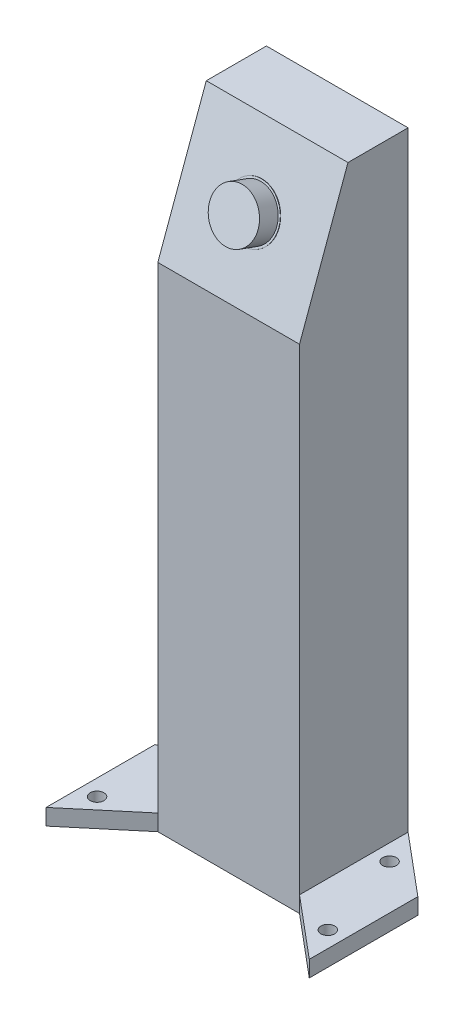
from build123d import *

# Parameters (mm, degrees)
AUFSATZ_LINEAR_AUSTRAGEN1_DEPTH = 35
SKIZZE3_R                       = 6
AUFSATZ_LINEAR_AUSTRAGEN2_DEPTH = 5
SKIZZE4_R                       = 6.5
AUFSATZ_LINEAR_AUSTRAGEN3_DEPTH = 0.1
SKIZZE9_R                       = 1.7
AUFSATZ_LINEAR_AUSTRAGEN4_DEPTH = 4


with BuildPart() as part:
    # Skizze1 → Aufsatz-Linear austragen1 (new body)
    with BuildSketch(Plane(origin=(0, 0, 0), x_dir=(0, 0, -1), z_dir=(1, 0, 0))):
        Polygon((0, 0), (11.970705016, 0), (26.82, 0), (26.82, 154.689241728), (11.970705016, 154.689241728), (0, 121.8), align=None)
    extrude(amount=AUFSATZ_LINEAR_AUSTRAGEN1_DEPTH)

    # Skizze3 → Aufsatz-Linear austragen2 (add)
    with BuildSketch(Plane(origin=(0, 14.247893414, 39.14576543), x_dir=(1, 0, 0), z_dir=(0, 0.342020143, 0.939692621))):
        with Locations((17.5, 131.954561212)):
            Circle(SKIZZE3_R)
    extrude(amount=AUFSATZ_LINEAR_AUSTRAGEN2_DEPTH)

    # Skizze4 → Aufsatz-Linear austragen3 (add)
    with BuildSketch(Plane(origin=(0, 14.247893414, 39.14576543), x_dir=(1, 0, 0), z_dir=(0, 0.342020143, 0.939692621))):
        with Locations((17.5, 131.954561212)):
            Circle(SKIZZE4_R)
    extrude(amount=AUFSATZ_LINEAR_AUSTRAGEN3_DEPTH)

    # Skizze9 → Aufsatz-Linear austragen4 (add)
    with BuildSketch(Plane.XZ):
        Polygon((35, -26.82), (50, -14.233505532), (50, 12.586494468), (35, 0), align=None)
        with Locations((46, 4.008466786)):
            Circle(SKIZZE9_R, mode=Mode.SUBTRACT)
        with Locations((39, -18.241972318)):
            Circle(SKIZZE9_R, mode=Mode.SUBTRACT)
        Polygon((0, 0), (0, -26.82), (-15, -14.233505532), (-15, 12.586494468), align=None)
        with Locations((-4, -18.241972318)):
            Circle(SKIZZE9_R, mode=Mode.SUBTRACT)
        with Locations((-11, 4.008466786)):
            Circle(SKIZZE9_R, mode=Mode.SUBTRACT)
    extrude(amount=-AUFSATZ_LINEAR_AUSTRAGEN4_DEPTH)


solid = part.part
